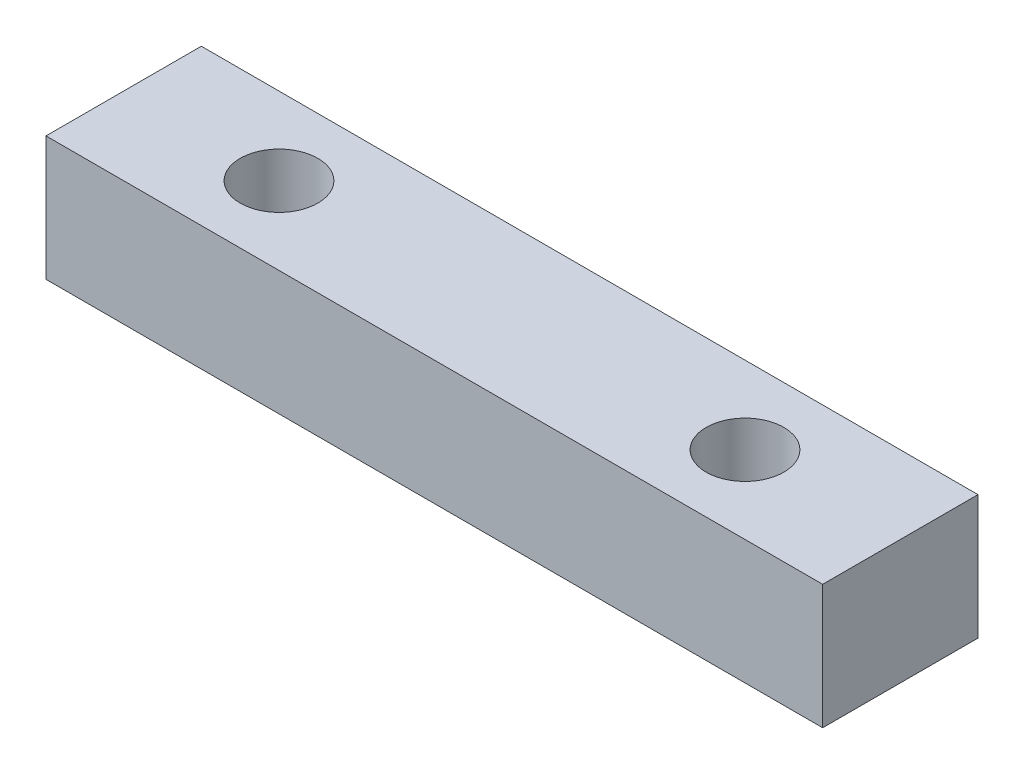
from build123d import *

# Parameters (mm, degrees)
SKETCH_1_W      = 25
SKETCH_1_H      = 5
SKETCH_1_R      = 1.25
EXTRUDE_1_DEPTH = 4


with BuildPart() as part:
    # 스케치1 → 보스-돌출1 (new body)
    with BuildSketch(Plane(origin=(0, 0, 0), x_dir=(1, 0, 0), z_dir=(0, 1, 0))):
        Rectangle(SKETCH_1_W, SKETCH_1_H)
        with Locations((7.5, 0)):
            Circle(SKETCH_1_R, mode=Mode.SUBTRACT)
        with Locations((-7.5, 0)):
            Circle(SKETCH_1_R, mode=Mode.SUBTRACT)
    extrude(amount=EXTRUDE_1_DEPTH)


solid = part.part
